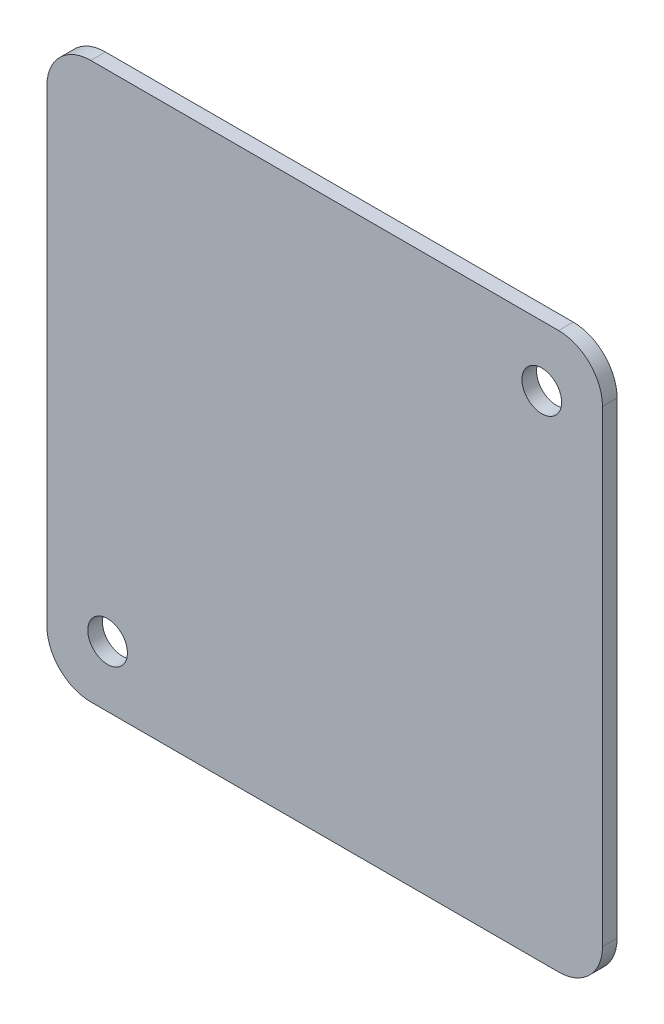
from build123d import *

# Parameters (mm, degrees)
BOSS_EXTRUDE1_DEPTH   = 1.5875
F_6_CLEARANCE_HOLE1_D = 4.3053


with BuildPart() as part:
    # Sketch1 → Boss-Extrude1 (new body)
    with BuildSketch(Plane.XY):
        with BuildLine():
            Line((-23.8125, -87.076434182), (-23.8125, -36.276434182))
            ThreePointArc((-23.8125, -36.276434182), (-25.207403955, -32.908838137), (-28.575, -31.513934182))
            Line((-28.575, -31.513934182), (-79.375, -31.513934182))
            ThreePointArc((-79.375, -31.513934182), (-82.742596045, -32.908838137), (-84.1375, -36.276434182))
            Line((-84.1375, -36.276434182), (-84.1375, -87.076434182))
            ThreePointArc((-84.1375, -87.076434182), (-82.742596045, -90.444030228), (-79.375, -91.838934182))
            Line((-79.375, -91.838934182), (-28.575, -91.838934182))
            ThreePointArc((-28.575, -91.838934182), (-25.207403955, -90.444030228), (-23.8125, -87.076434182))
        make_face()
    extrude(amount=-BOSS_EXTRUDE1_DEPTH)

    # #6 Clearance Hole1 (through all)
    with Locations(Plane(origin=(0, 0, -1.5875), x_dir=(-1, 0, 0), z_dir=(0, 0, -1))):
        with Locations((30.401827682, -38.103261864), (77.548172318, -85.2496065)):
            Hole(F_6_CLEARANCE_HOLE1_D / 2)


solid = part.part
